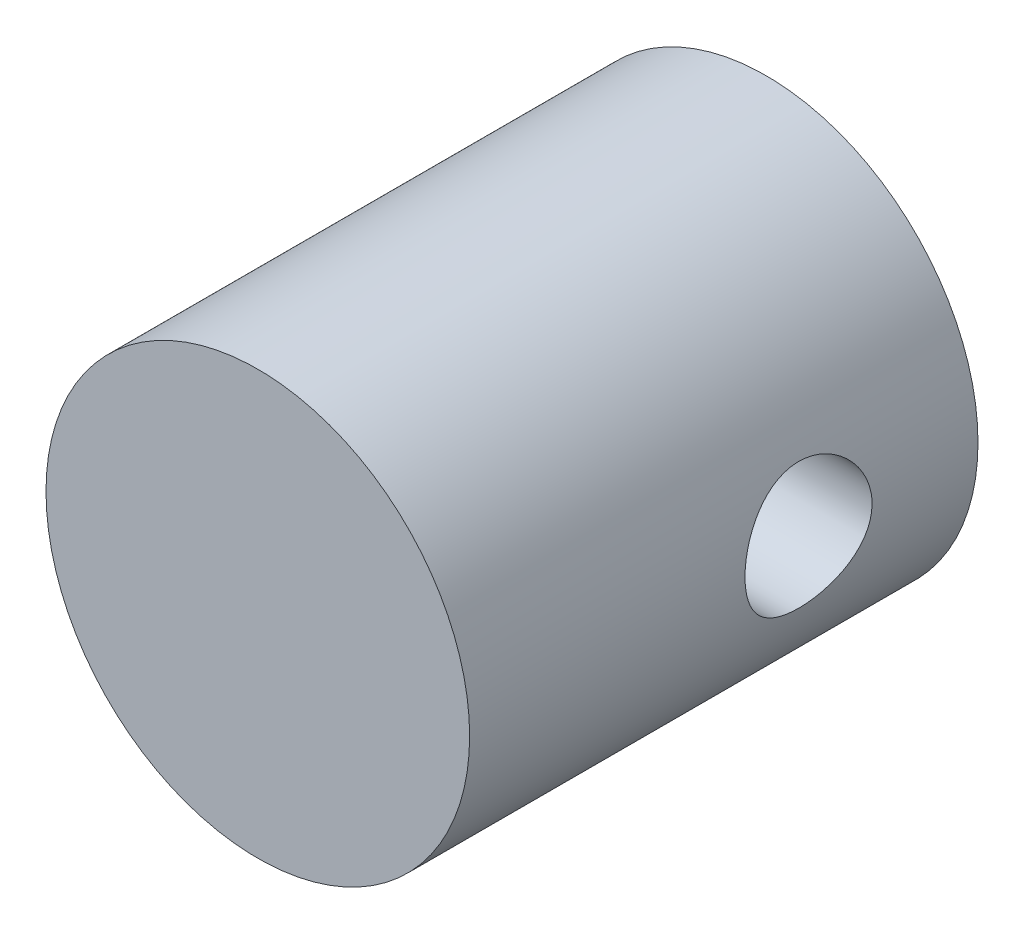
from build123d import *

# Parameters (mm, degrees)
SKETCH1_R               = 2.5
BOSS_EXTRUDE1_DEPTH     = 6
SKETCH2_R               = 0.75
CUT_EXTRUDE1_DEPTH      = 3.5
CUT_EXTRUDE1_DEPTH_BACK = 3.5


with BuildPart() as part:
    # Sketch1 → Boss-Extrude1 (new body)
    with BuildSketch(Plane.XY):
        Circle(SKETCH1_R)
    extrude(amount=BOSS_EXTRUDE1_DEPTH)

    # Sketch2 → Cut-Extrude1 (cut, two sides)
    with BuildSketch(Plane(origin=(0, 0, 0), x_dir=(0, 0, -1), z_dir=(1, 0, 0))) as cut_extrude1_sk:
        with Locations((-2, 0)):
            Circle(SKETCH2_R)
    extrude(amount=CUT_EXTRUDE1_DEPTH, mode=Mode.SUBTRACT)
    extrude(cut_extrude1_sk.sketch, amount=-CUT_EXTRUDE1_DEPTH_BACK, mode=Mode.SUBTRACT)


solid = part.part
